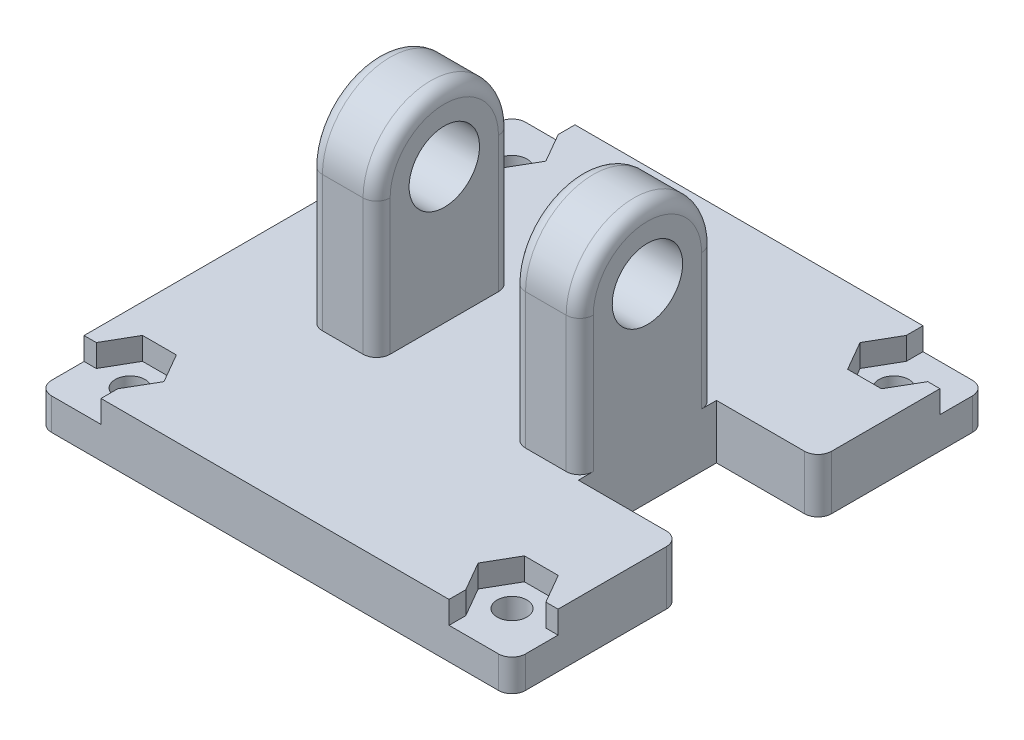
from build123d import *

# Parameters (mm, degrees)
ESQUISSE2_R             = 2.6
BOSS_EXTRU_1_DEPTH      = 10
ESQUISSE4_W             = 35
ESQUISSE4_H             = 35
BOSS_EXTRU_2_DEPTH      = 4
ENL_V_MAT_EXTRU_1_REACH = 6
ESQUISSE5_R             = 1.1
ESQUISSE6_W             = 10
ESQUISSE6_H             = 16.186441142
ENL_V_MAT_EXTRU_2_DEPTH = 23.5
ENL_V_MAT_EXTRU_3_DEPTH = 1.66
ENL_V_MAT_EXTRU_4_REACH = 6
ESQUISSE8_W             = 7.5
ESQUISSE8_H             = 10.2
CONG_1_R                = 1
ENL_V_MAT_EXTRU_5_DEPTH = 1.66


with BuildPart() as part:
    # Esquisse2 → Boss.-Extru.1 (new body, symmetric)
    with BuildSketch(Plane(origin=(0, 0, 0), x_dir=(0, 0, -1), z_dir=(1, 0, 0))):
        with BuildLine():
            Line((5, 0), (5, -10))
            Line((5, -10), (-5, -10))
            Line((-5, -10), (-5, 0))
            ThreePointArc((-5, 0), (0, 5), (5, 0))
        make_face()
        Circle(ESQUISSE2_R, mode=Mode.SUBTRACT)
    extrude(amount=BOSS_EXTRU_1_DEPTH, both=True)

    # Esquisse4 → Boss.-Extru.2 (add)
    with BuildSketch(Plane.XZ.offset(10)):
        Rectangle(ESQUISSE4_W, ESQUISSE4_H)
    extrude(amount=BOSS_EXTRU_2_DEPTH)

    # Esquisse5 → Enlèv. mat.-Extru.1 (cut, up to next)
    with BuildSketch(Plane(origin=(0, -10, 0), x_dir=(1, 0, 0), z_dir=(0, 1, 0)), mode=Mode.PRIVATE) as enl_v_mat_extru_1_sk1:
        with Locations(Location((14.1, -14.1, 0), (0, 0, 270))):  # turned: the seam where the file's is
            Circle(ESQUISSE5_R)
    enl_v_mat_extru_1_tool1 = extrude(enl_v_mat_extru_1_sk1.sketch, amount=-ENL_V_MAT_EXTRU_1_REACH, mode=Mode.PRIVATE) & part.part
    add(enl_v_mat_extru_1_tool1.solids().sort_by_distance((14.1, -10, 14.1))[0], mode=Mode.SUBTRACT)
    # Esquisse5 → Enlèv. mat.-Extru.1 (cut, up to next)
    with BuildSketch(Plane(origin=(0, -10, 0), x_dir=(1, 0, 0), z_dir=(0, 1, 0)), mode=Mode.PRIVATE) as enl_v_mat_extru_1_sk2:
        with Locations(Location((14.1, 14.1, 0), (0, 0, 270))):  # turned: the seam where the file's is
            Circle(ESQUISSE5_R)
    enl_v_mat_extru_1_tool2 = extrude(enl_v_mat_extru_1_sk2.sketch, amount=-ENL_V_MAT_EXTRU_1_REACH, mode=Mode.PRIVATE) & part.part
    add(enl_v_mat_extru_1_tool2.solids().sort_by_distance((14.1, -10, -14.1))[0], mode=Mode.SUBTRACT)
    # Esquisse5 → Enlèv. mat.-Extru.1 (cut, up to next)
    with BuildSketch(Plane(origin=(0, -10, 0), x_dir=(1, 0, 0), z_dir=(0, 1, 0)), mode=Mode.PRIVATE) as enl_v_mat_extru_1_sk3:
        with Locations(Location((-14.1, 14.1, 0), (0, 0, 270))):  # turned: the seam where the file's is
            Circle(ESQUISSE5_R)
    enl_v_mat_extru_1_tool3 = extrude(enl_v_mat_extru_1_sk3.sketch, amount=-ENL_V_MAT_EXTRU_1_REACH, mode=Mode.PRIVATE) & part.part
    add(enl_v_mat_extru_1_tool3.solids().sort_by_distance((-14.1, -10, -14.1))[0], mode=Mode.SUBTRACT)
    # Esquisse5 → Enlèv. mat.-Extru.1 (cut, up to next)
    with BuildSketch(Plane(origin=(0, -10, 0), x_dir=(1, 0, 0), z_dir=(0, 1, 0)), mode=Mode.PRIVATE) as enl_v_mat_extru_1_sk4:
        with Locations(Location((-14.1, -14.1, 0), (0, 0, 270))):  # turned: the seam where the file's is
            Circle(ESQUISSE5_R)
    enl_v_mat_extru_1_tool4 = extrude(enl_v_mat_extru_1_sk4.sketch, amount=-ENL_V_MAT_EXTRU_1_REACH, mode=Mode.PRIVATE) & part.part
    add(enl_v_mat_extru_1_tool4.solids().sort_by_distance((-14.1, -10, 14.1))[0], mode=Mode.SUBTRACT)

    # Esquisse6 → Enlèv. mat.-Extru.2 (cut, through all)
    with BuildSketch(Plane.XY.offset(5)):
        with Locations((0, -1.906779429)):
            Rectangle(ESQUISSE6_W, ESQUISSE6_H)
    extrude(amount=-ENL_V_MAT_EXTRU_2_DEPTH, mode=Mode.SUBTRACT)

    # Esquisse7 → Enlèv. mat.-Extru.3 (cut)
    with BuildSketch(Plane(origin=(0, -10, 0), x_dir=(1, 0, 0), z_dir=(0, 1, 0))):
        Polygon((-11.6, -14.1), (-12.85, -11.934936491), (-15.35, -11.934936491), (-16.6, -14.1), (-15.35, -16.265063509), (-12.85, -16.265063509), align=None)
        Polygon((16.6, -14.1), (15.35, -11.934936491), (12.85, -11.934936491), (11.6, -14.1), (12.85, -16.265063509), (15.35, -16.265063509), align=None)
        Polygon((16.6, 14.1), (15.35, 16.265063509), (12.85, 16.265063509), (11.6, 14.1), (12.85, 11.934936491), (15.35, 11.934936491), align=None)
        Polygon((-11.6, 14.1), (-12.85, 16.265063509), (-15.35, 16.265063509), (-16.6, 14.1), (-15.35, 11.934936491), (-12.85, 11.934936491), align=None)
    extrude(amount=-ENL_V_MAT_EXTRU_3_DEPTH, mode=Mode.SUBTRACT)

    # Esquisse8 → Enlèv. mat.-Extru.4 (cut, up to next)
    with BuildSketch(Plane(origin=(0, -10, 0), x_dir=(1, 0, 0), z_dir=(0, 1, 0)), mode=Mode.PRIVATE) as enl_v_mat_extru_4_sk1:
        with Locations((13.75, 0)):
            Rectangle(ESQUISSE8_W, ESQUISSE8_H)
    enl_v_mat_extru_4_tool1 = extrude(enl_v_mat_extru_4_sk1.sketch, amount=-ENL_V_MAT_EXTRU_4_REACH, mode=Mode.PRIVATE) & part.part
    add(enl_v_mat_extru_4_tool1.solids().sort_by_distance((13.75, -10, 0))[0], mode=Mode.SUBTRACT)

    # Congé1
    cong_1_edges = [part.edges().sort_by_distance(p)[0] for p in [
        (17.5, -12, -5.1),
        (17.5, -12, 5.1),
        (10, -5, -5),
        (-17.5, -12, 17.5),
        (-17.5, -12, -17.5),
        (17.5, -12, -17.5),
        (17.5, -12, 17.5),
        (10, 5, 0),
        (-10, -5, -5),
        (-5, 5, 0),
        (-5, -5, -5),
        (5, -5, -5),
        (5, 5, 0),
        (5, -5, 5),
        (-5, -5, 5),
        (-10, -5, 5),
        (-10, 5, 0),
        (10, -5, 5),
    ]]
    fillet(cong_1_edges, radius=CONG_1_R)

    # Esquisse9 → Enlèv. mat.-Extru.5 (cut)
    with BuildSketch(Plane(origin=(0, -10, 0), x_dir=(1, 0, 0), z_dir=(0, 1, 0))):
        Polygon((-12.85, 16.265063509), (-12.85, 18.698665102), (-21.49528431, 18.698665102), (-21.49528431, 14.1), (-16.6, 14.1), align=None)
        Polygon((12.85, 16.265063509), (16.6, 14.1), (20.960231463, 14.1), (20.960231463, 18.699687557), (12.85, 18.699687557), align=None)
        Polygon((16.6, -14.1), (12.85, -16.265063509), (12.85, -19.961421422), (19.488454623, -19.961421422), (19.488454623, -14.1), align=None)
        Polygon((-12.85, -16.265063509), (-16.6, -14.1), (-22.379616977, -14.1), (-22.379616977, -21.035530628), (-12.85, -21.035530628), align=None)
    extrude(amount=-ENL_V_MAT_EXTRU_5_DEPTH, mode=Mode.SUBTRACT)


solid = part.part
